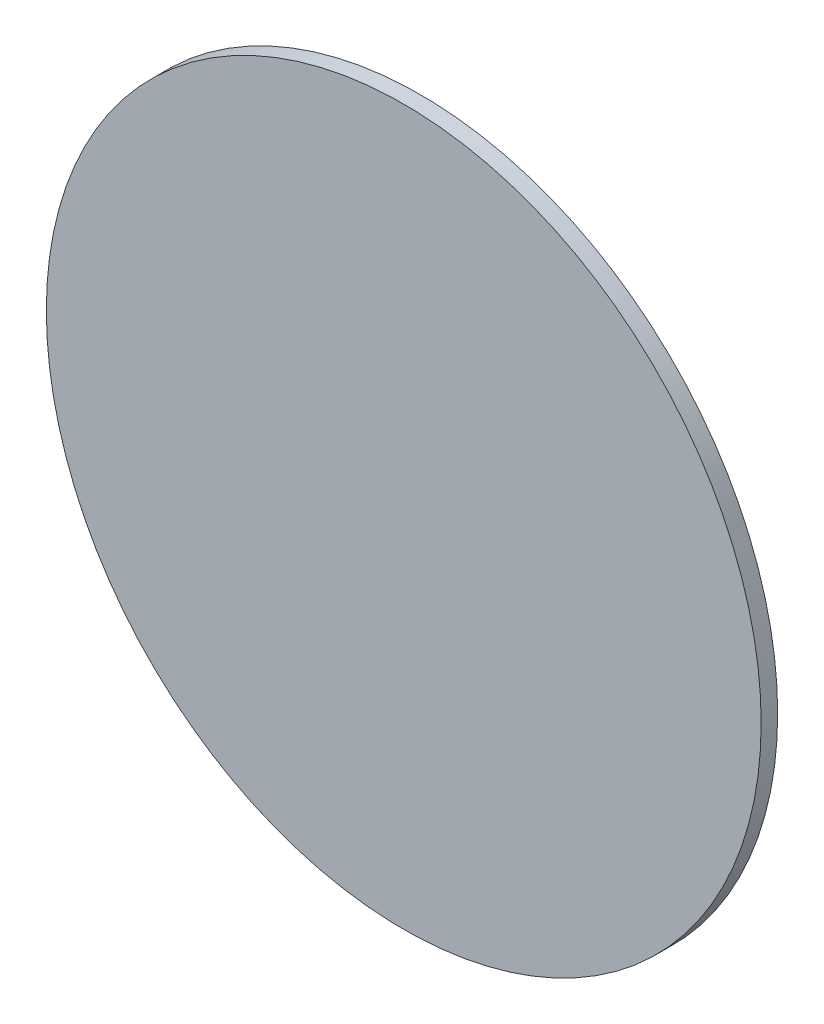
from build123d import *

# Parameters (mm, degrees)
SKETCH_1_R      = 16
SKETCH_1_R_2    = 11.5
EXTRUDE_1_DEPTH = 19
SKETCH_2_R      = 65
EXTRUDE_2_DEPTH = 3


with BuildPart() as part:
    # Эскиз1 → Бобышка-Вытянуть1 (new body)
    with BuildSketch(Plane.XY):
        Circle(SKETCH_1_R)
        Circle(SKETCH_1_R_2, mode=Mode.SUBTRACT)
    extrude(amount=EXTRUDE_1_DEPTH)

    # Эскиз2 → Бобышка-Вытянуть2 (add)
    with BuildSketch(Plane.XY.offset(19)):
        Circle(SKETCH_2_R)
    extrude(amount=EXTRUDE_2_DEPTH)


solid = part.part
